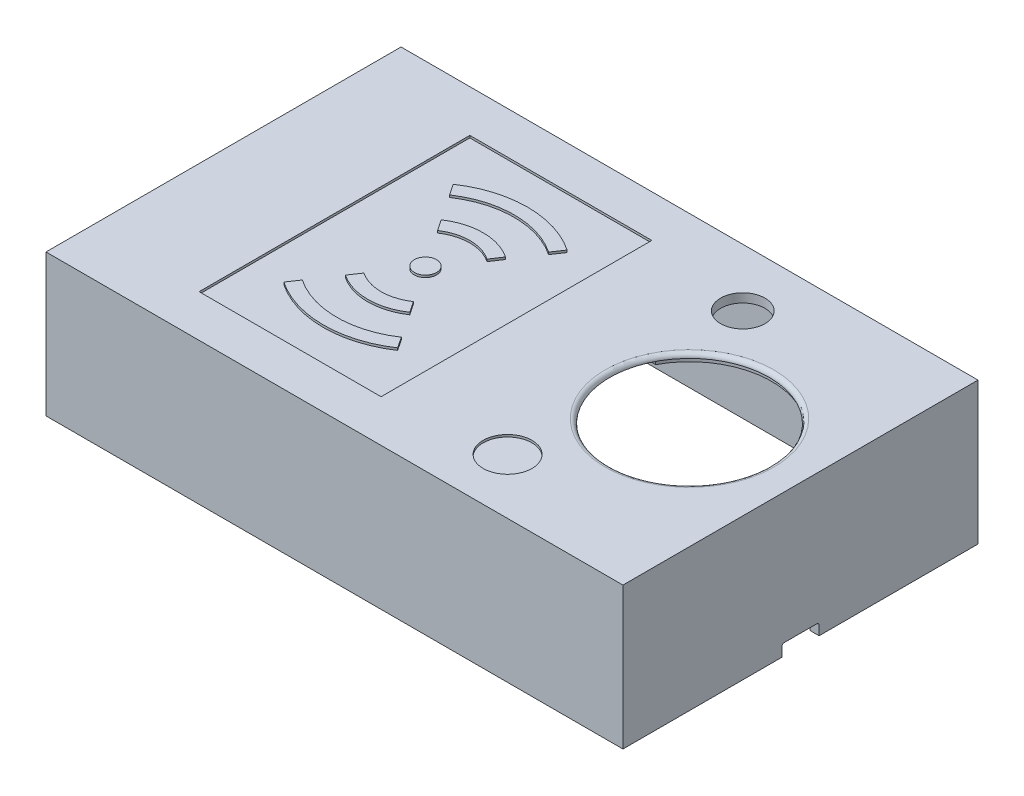
from build123d import *

# Parameters (mm, degrees)
ESQUISSE1_W                  = 130
ESQUISSE1_H                  = 80
BOSS_EXTRU_1_DEPTH           = 2
ESQUISSE2_W                  = 130
ESQUISSE2_H                  = 80
ESQUISSE2_R                  = 5.1
BOSS_EXTRU_2_DEPTH           = 30
ESQUISSE8_R                  = 5.5
BOSS_EXTRU_6_DEPTH           = 5
ENL_V_MAT_EXTRU_1_DEPTH      = 156.563491861
ENL_V_MAT_EXTRU_1_DEPTH_BACK = 156.563491861
ESQUISSE3_R                  = 18
ESQUISSE3_R_2                = 5
CONG_1_R                     = 1
ESQUISSE5_R                  = 5.5
ESQUISSE5_W                  = 41
ESQUISSE5_H                  = 61
ENL_V_MAT_EXTRU_2_DEPTH      = 0.5
ESQUISSE7_R                  = 2.5
BOSS_EXTRU_5_DEPTH           = 0.5
ENL_V_MAT_EXTRU_3_DEPTH      = 1
BOSS_EXTRU_8_DEPTH           = 3
CONG_2_R                     = 0.8
CONG_3_R                     = 0.8
ENL_V_MAT_EXTRU_4_DEPTH      = 3
ENL_V_START                  = 17
ENL_V_MAT_EXTRU_5_DEPTH      = 17
ENL_V_MAT_EXTRU_6_DEPTH      = 17
ENL_V_START_2                = 11
ENL_V_MAT_EXTRU_7_DEPTH      = 11
ESQUISSE23_W                 = 8.4
ESQUISSE23_H                 = 2.6
ENL_V_MAT_EXTRU_8_DEPTH      = 11
CONG_4_R                     = 0.5


with BuildPart() as part:
    # Esquisse1 → Boss.-Extru.1 (new body)
    with BuildSketch(Plane(origin=(0, 0, 0), x_dir=(1, 0, 0), z_dir=(0, 1, 0))):
        with Locations((65, 40)):
            Rectangle(ESQUISSE1_W, ESQUISSE1_H)
    extrude(amount=BOSS_EXTRU_1_DEPTH)

    # Esquisse2 → Boss.-Extru.2 (add)
    with BuildSketch(Plane.XZ):
        with Locations((65, -40)):
            Rectangle(ESQUISSE2_W, ESQUISSE2_H)
        with Locations((123, -7)):
            Circle(ESQUISSE2_R, mode=Mode.SUBTRACT)
        with Locations((123, -73)):
            Circle(ESQUISSE2_R, mode=Mode.SUBTRACT)
        with Locations((7, -7)):
            Circle(ESQUISSE2_R, mode=Mode.SUBTRACT)
        with Locations((7, -73)):
            Circle(ESQUISSE2_R, mode=Mode.SUBTRACT)
        with BuildLine():
            Line((11.898979486, -78), (118.101020514, -78))
            ThreePointArc((118.101020514, -78), (118.050252532, -68.050252532), (128, -68.101020514))
            Line((128, -68.101020514), (128, -11.898979486))
            ThreePointArc((128, -11.898979486), (118.050252532, -11.949747468), (118.101020514, -2))
            Line((118.101020514, -2), (11.898979486, -2))
            ThreePointArc((11.898979486, -2), (11.949747468, -11.949747468), (2, -11.898979486))
            Line((2, -11.898979486), (2, -68.101020514))
            ThreePointArc((2, -68.101020514), (11.949747468, -68.050252532), (11.898979486, -78))
        make_face(mode=Mode.SUBTRACT)
    extrude(amount=BOSS_EXTRU_2_DEPTH)

    # Esquisse8 → Boss.-Extru.6 (add)
    with BuildSketch(Plane.XZ):
        with Locations((123, -7)):
            Circle(ESQUISSE8_R)
        with Locations((7, -7)):
            Circle(ESQUISSE8_R)
        with Locations((7, -73)):
            Circle(ESQUISSE8_R)
        with Locations((123, -73)):
            Circle(ESQUISSE8_R)
    extrude(amount=BOSS_EXTRU_6_DEPTH)

    # Esquisse3 → Enl_v. mat.-Extru.1 (cut, two sides: drawn at the far end of the back side and taken through both)
    with BuildSketch(Plane.XZ.offset(-ENL_V_MAT_EXTRU_1_DEPTH_BACK)):
        with Locations((105, -40)):
            Circle(ESQUISSE3_R)
        with Locations((90, -67)):
            Circle(ESQUISSE3_R_2)
    extrude(amount=ENL_V_MAT_EXTRU_1_DEPTH + ENL_V_MAT_EXTRU_1_DEPTH_BACK, mode=Mode.SUBTRACT)

    # Cong_1
    cong_1_edges = [part.edges().sort_by_distance(p)[0] for p in [
        (87, 2, -40),
    ]]
    fillet(cong_1_edges, radius=CONG_1_R)

    # Esquisse5 → Enl_v. mat.-Extru.2 (cut)
    with BuildSketch(Plane(origin=(0, 2, 0), x_dir=(1, 0, 0), z_dir=(0, 1, 0))):
        with Locations((91.5, 12.5)):
            Circle(ESQUISSE5_R)
        with Locations((45.5, 40)):
            Rectangle(ESQUISSE5_W, ESQUISSE5_H)
    extrude(amount=-ENL_V_MAT_EXTRU_2_DEPTH, mode=Mode.SUBTRACT)

    # Esquisse7 → Boss.-Extru.5 (add)
    with BuildSketch(Plane(origin=(0, 1.5, 0), x_dir=(1, 0, 0), z_dir=(0, 1, 0))):
        with Locations((45.5, 40)):
            Circle(ESQUISSE7_R)
        with BuildLine():
            Line((32.669771151, 59.088877067), (34.343279262, 56.599023537))
            ThreePointArc((34.343279262, 56.599023537), (45.5, 60), (56.656720738, 56.599023537))
            Line((56.656720738, 56.599023537), (58.330228849, 59.088877067))
            ThreePointArc((58.330228849, 59.088877067), (45.5, 63), (32.669771151, 59.088877067))
        make_face()
        with BuildLine():
            Line((38.24813152, 50.789365299), (39.921639631, 48.299511768))
            ThreePointArc((39.921639631, 48.299511768), (45.5, 50), (51.078360369, 48.299511768))
            Line((51.078360369, 48.299511768), (52.75186848, 50.789365299))
            ThreePointArc((52.75186848, 50.789365299), (45.5, 53), (38.24813152, 50.789365299))
        make_face()
        with BuildLine():
            Line((51.078360369, 31.700488232), (52.75186848, 29.210634701))
            ThreePointArc((52.75186848, 29.210634701), (45.5, 27), (38.24813152, 29.210634701))
            Line((38.24813152, 29.210634701), (39.921639631, 31.700488232))
            ThreePointArc((39.921639631, 31.700488232), (45.5, 30), (51.078360369, 31.700488232))
        make_face()
        with BuildLine():
            Line((34.343279262, 23.400976463), (32.669771151, 20.911122933))
            ThreePointArc((32.669771151, 20.911122933), (45.5, 17), (58.330228849, 20.911122933))
            Line((58.330228849, 20.911122933), (56.656720738, 23.400976463))
            ThreePointArc((56.656720738, 23.400976463), (45.5, 20), (34.343279262, 23.400976463))
        make_face()
    extrude(amount=BOSS_EXTRU_5_DEPTH)

    # Esquisse9 → Enl_v. mat.-Extru.3 (cut)
    with BuildSketch(Plane.XZ):
        with BuildLine():
            Line((78.6, -31.3), (88.673334694, -31.3))
            ThreePointArc((88.673334694, -31.3), (123.5, -40), (88.673334694, -48.7))
            Line((88.673334694, -48.7), (78.6, -48.7))
            Line((78.6, -48.7), (78.6, -31.3))
        make_face()
    extrude(amount=-ENL_V_MAT_EXTRU_3_DEPTH, mode=Mode.SUBTRACT)

    # Esquisse18 → Boss.-Extru.8 (add)
    with BuildSketch(Plane.ZY.offset(-88.5)):
        Polygon((-7.75, 0), (-4.75, 0), (-5.75, -6.5), (-6.75, -6.5), (-7.5, -5), (-6.75, -5), (-6.75, -3), (-7.75, -3), align=None)
        Polygon((-17.25, 0), (-17.25, -3), (-18.25, -3), (-18.25, -5), (-17.5, -5), (-18.25, -6.5), (-19.25, -6.5), (-20.25, 0), align=None)
    extrude(amount=BOSS_EXTRU_8_DEPTH)

    # Cong_2
    cong_2_edges = [part.edges().sort_by_distance(p)[0] for p in [
        (85.5, 0, -6.25),
        (87, 0, -4.75),
        (87, 0, -7.75),
        (88.5, 0, -6.25),
        (88.5, 0, -18.75),
        (87, 0, -20.25),
        (87, 0, -17.25),
        (85.5, 0, -18.75),
    ]]
    fillet(cong_2_edges, radius=CONG_2_R)

    # Esquisse19 → R_volution1 (revolve)
    with BuildSketch(Plane(origin=(29.5, 0, 0), x_dir=(0, 0, -1), z_dir=(1, 0, 0))):
        Polygon((55, 0), (56.85, 0), (56.85, -5), (57, -5), (56.1, -7.9), (55, -7.9), align=None)
    revolve(axis=Axis((29.5, 0, -55), (0, -1, 0)))

    # Esquisse20 → R_volution2 (revolve)
    with BuildSketch(Plane(origin=(59.5, 0, 0), x_dir=(0, 0, -1), z_dir=(1, 0, 0))):
        Polygon((18.5, 0), (20.35, 0), (20.35, -5), (20.5, -5), (19.6, -7.9), (18.5, -7.9), align=None)
    revolve(axis=Axis((59.5, 0, -18.5), (0, -1, 0)))

    # Cong_3
    cong_3_edges = [part.edges().sort_by_distance(p)[0] for p in [
        (29.5, 0, -53.15),
        (59.5, 0, -16.65),
    ]]
    fillet(cong_3_edges, radius=CONG_3_R)

    # Esquisse21 → Enl_v. mat.-Extru.4 (cut)
    with BuildSketch(Plane(origin=(29.5, 0, 0), x_dir=(0, 0, -1), z_dir=(1, 0, 0))):
        with BuildLine():
            Line((54.625, -10.5), (54.625, -0.5))
            ThreePointArc((54.625, -0.5), (55, -0.125), (55.375, -0.5))
            Line((55.375, -0.5), (55.375, -10.5))
            Line((55.375, -10.5), (54.625, -10.5))
        make_face()
    extrude(amount=-ENL_V_MAT_EXTRU_4_DEPTH, mode=Mode.SUBTRACT)

    # Esquisse21_2 → Enl_v. mat.-Extru.5 (cut)
    with BuildSketch(Plane(origin=(29.5, 0, 0), x_dir=(0, 0, -1), z_dir=(1, 0, 0)).offset(ENL_V_START)):
        with BuildLine():
            Line((54.625, -10.5), (54.625, -0.5))
            ThreePointArc((54.625, -0.5), (55, -0.125), (55.375, -0.5))
            Line((55.375, -0.5), (55.375, -10.5))
            Line((55.375, -10.5), (54.625, -10.5))
        make_face()
    extrude(amount=-ENL_V_MAT_EXTRU_5_DEPTH, mode=Mode.SUBTRACT)

    # Esquisse22 → Enl_v. mat.-Extru.6 (cut)
    with BuildSketch(Plane(origin=(59.5, 0, 0), x_dir=(0, 0, -1), z_dir=(1, 0, 0))):
        with BuildLine():
            Line((18.125, -0.5), (18.125, -10.5))
            Line((18.125, -10.5), (18.875, -10.5))
            Line((18.875, -10.5), (18.875, -0.5))
            ThreePointArc((18.875, -0.5), (18.5, -0.125), (18.125, -0.5))
        make_face()
    extrude(amount=-ENL_V_MAT_EXTRU_6_DEPTH, mode=Mode.SUBTRACT)

    # Esquisse22_2 → Enl_v. mat.-Extru.7 (cut)
    with BuildSketch(Plane(origin=(59.5, 0, 0), x_dir=(0, 0, -1), z_dir=(1, 0, 0)).offset(ENL_V_START_2)):
        with BuildLine():
            Line((18.125, -0.5), (18.125, -10.5))
            Line((18.125, -10.5), (18.875, -10.5))
            Line((18.875, -10.5), (18.875, -0.5))
            ThreePointArc((18.875, -0.5), (18.5, -0.125), (18.125, -0.5))
        make_face()
    extrude(amount=-ENL_V_MAT_EXTRU_7_DEPTH, mode=Mode.SUBTRACT)

    # Esquisse23 → Enl_v. mat.-Extru.8 (cut)
    with BuildSketch(Plane(origin=(130, 0, 0), x_dir=(0, 0, -1), z_dir=(1, 0, 0))):
        with Locations((40, -28.7)):
            Rectangle(ESQUISSE23_W, ESQUISSE23_H)
    extrude(amount=-ENL_V_MAT_EXTRU_8_DEPTH, mode=Mode.SUBTRACT)

    # Cong_4
    cong_4_edges = [part.edges().sort_by_distance(p)[0] for p in [
        (129, -27.4, -35.8),
        (129, -27.4, -44.2),
    ]]
    fillet(cong_4_edges, radius=CONG_4_R)


solid = part.part
